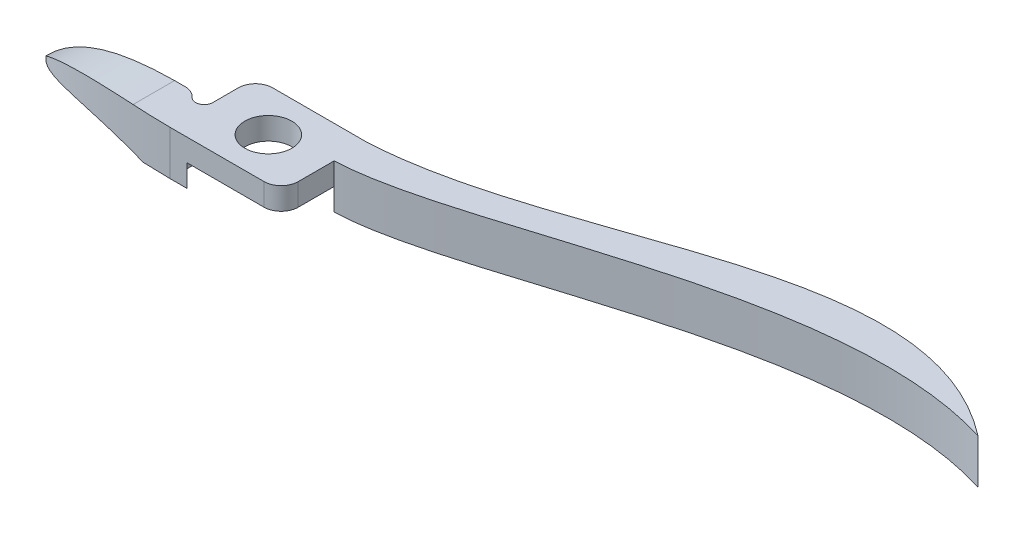
from build123d import *

# Parameters (mm, degrees)
SKETCH1_R           = 3.4925
BOSS_EXTRUDE3_DEPTH = 3.302
BOSS_EXTRUDE4_DEPTH = 3.302
BOSS_EXTRUDE5_DEPTH = 3.302
CUT_EXTRUDE1_REACH  = 8.35


with BuildPart() as part:
    # Sketch1 → Boss-Extrude3 (new body)
    with BuildSketch(Plane(origin=(0, 0, 0), x_dir=(1, 0, 0), z_dir=(0, 1, 0))):
        with BuildLine():
            ThreePointArc((-10.47160211, -0.846666667), (-11.327855674, -0.22130784), (-12.364806331, 0))
            Line((-12.364806331, 0), (-33.02, 0))
            add(Edge.make_bspline(
                [(-33.02, 0), (-27.473096433, -6.223159861), (-8.255, -6.35)],
                knots=[0, 0, 0, 1, 1, 1], degree=2))
            Line((-8.255, -6.35), (-8.255, -3.81))
            Line((-8.255, -3.81), (-8.255, 0))
            ThreePointArc((-8.255, 0), (-9.071835946, -1.186398896), (-10.47160211, -0.846666667))
        make_face()
        with BuildLine():
            ThreePointArc((5.715, 6.35), (7.511051224, 5.606051224), (8.255, 3.81))
            Line((8.255, 3.81), (8.255, -3.81))
            ThreePointArc((8.255, -3.81), (7.511051224, -5.606051224), (5.715, -6.35))
            Line((5.715, -6.35), (-5.715, -6.35))
            ThreePointArc((-5.715, -6.35), (-7.511051224, -5.606051224), (-8.255, -3.81))
            Line((-8.255, -3.81), (-8.255, 3.81))
            ThreePointArc((-8.255, 3.81), (-7.511051224, 5.606051224), (-5.715, 6.35))
            Line((-5.715, 6.35), (5.715, 6.35))
        make_face()
        with Locations(Location((0, 0, 0), (0, 0, 270))):  # turned: the seam where the file's is
            Circle(SKETCH1_R, mode=Mode.SUBTRACT)
        with BuildLine():
            ThreePointArc((-8.255, -3.81), (-7.511051224, -5.606051224), (-5.715, -6.35))
            Line((-5.715, -6.35), (-8.255, -6.35))
            Line((-8.255, -6.35), (-8.255, -3.81))
        make_face()
        with BuildLine():
            Line((8.255, 3.527942587), (8.255, 1.524))
            add(Edge.make_bspline(
                [(8.255, 1.524), (26.922144182, 2.150849617), (62.646246262, 22.822886738), (91.44, 13.97)],
                knots=[0, 0, 0, 0, 1, 1, 1, 1], degree=3))
            add(Edge.make_bspline(
                [(91.44, 13.97), (66.350363848, 33.352051218), (36.841337127, 7.764653999), (8.255, 6.35)],
                knots=[0, 0, 0, 0, 1, 1, 1, 1], degree=3))
            Line((8.255, 6.35), (8.255, 3.81))
            Line((8.255, 3.81), (8.255, 3.527942587))
        make_face()
        with BuildLine():
            Line((8.255, 6.35), (5.715, 6.35))
            ThreePointArc((5.715, 6.35), (7.511051224, 5.606051224), (8.255, 3.81))
            Line((8.255, 3.81), (8.255, 6.35))
        make_face()
    extrude(amount=BOSS_EXTRUDE3_DEPTH)

    # Sketch1_8 → Boss-Extrude4 (add)
    with BuildSketch(Plane(origin=(0, 0, 0), x_dir=(1, 0, 0), z_dir=(0, 1, 0))):
        with BuildLine():
            Line((8.255, 3.527942587), (8.255, 1.524))
            add(Edge.make_bspline(
                [(8.255, 1.524), (26.922144182, 2.150849617), (62.646246262, 22.822886738), (91.44, 13.97)],
                knots=[0, 0, 0, 0, 1, 1, 1, 1], degree=3))
            add(Edge.make_bspline(
                [(91.44, 13.97), (66.350363848, 33.352051218), (36.841337127, 7.764653999), (8.255, 6.35)],
                knots=[0, 0, 0, 0, 1, 1, 1, 1], degree=3))
            Line((8.255, 6.35), (8.255, 3.81))
            Line((8.255, 3.81), (8.255, 3.527942587))
        make_face()
        with BuildLine():
            Line((8.255, 6.35), (5.715, 6.35))
            ThreePointArc((5.715, 6.35), (7.511051224, 5.606051224), (8.255, 3.81))
            Line((8.255, 3.81), (8.255, 6.35))
        make_face()
    extrude(amount=-BOSS_EXTRUDE4_DEPTH)

    # Sketch1_9 → Boss-Extrude5 (add)
    with BuildSketch(Plane(origin=(0, 0, 0), x_dir=(1, 0, 0), z_dir=(0, 1, 0))):
        with BuildLine():
            ThreePointArc((-10.47160211, -0.846666667), (-11.327855674, -0.22130784), (-12.364806331, 0))
            Line((-12.364806331, 0), (-33.02, 0))
            add(Edge.make_bspline(
                [(-33.02, 0), (-27.473096433, -6.223159861), (-8.255, -6.35)],
                knots=[0, 0, 0, 1, 1, 1], degree=2))
            Line((-8.255, -6.35), (-8.255, -3.81))
            Line((-8.255, -3.81), (-8.255, 0))
            ThreePointArc((-8.255, 0), (-9.071835946, -1.186398896), (-10.47160211, -0.846666667))
        make_face()
        with BuildLine():
            ThreePointArc((-8.255, -3.81), (-7.511051224, -5.606051224), (-5.715, -6.35))
            Line((-5.715, -6.35), (-8.255, -6.35))
            Line((-8.255, -6.35), (-8.255, -3.81))
        make_face()
    extrude(amount=-BOSS_EXTRUDE5_DEPTH)

    # Sketch2 → Cut-Extrude1 (cut, up to next)
    with BuildSketch(Plane.XY, mode=Mode.PRIVATE) as cut_extrude1_sk1:
        with BuildLine():
            Line((-33.02, 3.302), (-33.02, -3.053994927))
            add(Edge.make_bspline(
                [(-33.02, -3.053994927), (-28.519594092, 1.640722514), (-22.101826858, 3.211473856), (-13.921878912, 3.302)],
                knots=[0, 0, 0, 0, 0.941080878, 0.941080878, 0.941080878, 0.941080878], degree=3))
            Line((-13.921878912, 3.302), (-33.02, 3.302))
        make_face()
    cut_extrude1_tool1 = extrude(cut_extrude1_sk1.sketch, amount=CUT_EXTRUDE1_REACH, mode=Mode.PRIVATE) & part.part
    add(cut_extrude1_tool1.solids().sort_by_distance((-28.707051, 1.545014, 0))[0], mode=Mode.SUBTRACT)
    # Sketch2 → Cut-Extrude1 (cut, up to next)
    with BuildSketch(Plane.XY, mode=Mode.PRIVATE) as cut_extrude1_sk2:
        with BuildLine():
            Line((-12.364806331, -3.302), (-33.02, -3.302))
            add(Edge.make_bspline(
                [(-12.364806331, -3.302), (-18.804874471, -1.031483357), (-26.812471442, -0.753963495), (-33.02, -3.302)],
                knots=[0, 0, 0, 0, 1, 1, 1, 1], degree=3))
        make_face()
    cut_extrude1_tool2 = extrude(cut_extrude1_sk2.sketch, amount=CUT_EXTRUDE1_REACH, mode=Mode.PRIVATE) & part.part
    add(cut_extrude1_tool2.solids().sort_by_distance((-22.84596, -2.573969, 0))[0], mode=Mode.SUBTRACT)


solid = part.part
